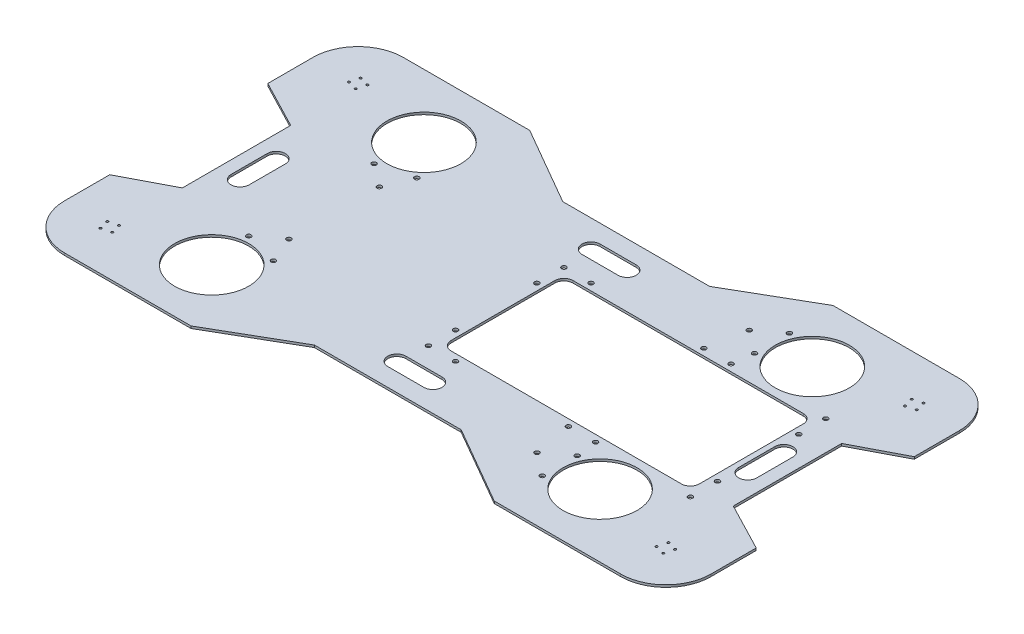
from build123d import *

# Parameters (mm, degrees)
SKETCH1_R           = 52.07
SKETCH1_R_2         = 1.575
BOSS_EXTRUDE1_DEPTH = 3.175
SKETCH2_R           = 3.2639
CUT_EXTRUDE1_DEPTH  = 4.175
SKETCH3_R           = 3.2639
CUT_EXTRUDE2_DEPTH  = 4.175
CUT_EXTRUDE3_DEPTH  = 4.175
CUT_EXTRUDE4_DEPTH  = 4.175


with BuildPart() as part:
    # Sketch1 → Boss-Extrude1 (new body)
    with BuildSketch(Plane(origin=(0, 0, 0), x_dir=(1, 0, 0), z_dir=(0, 1, 0))):
        with BuildLine():
            Line((387.35, 76.2), (387.35, -76.2))
            Line((387.35, -76.2), (454.496015193, -111.125))
            Line((454.496015193, -111.125), (454.496015193, -174.625))
            ThreePointArc((454.496015193, -174.625), (435.897295799, -219.526280605), (390.996015193, -238.125))
            Line((390.996015193, -238.125), (213.196015193, -238.125))
            Line((213.196015193, -238.125), (103.210788913, -174.625))
            Line((103.210788913, -174.625), (-103.210788913, -174.625))
            Line((-103.210788913, -174.625), (-213.196015193, -238.125))
            Line((-213.196015193, -238.125), (-390.996015193, -238.125))
            ThreePointArc((-390.996015193, -238.125), (-435.897295799, -219.526280605), (-454.496015193, -174.625))
            Line((-454.496015193, -174.625), (-454.496015193, -111.125))
            Line((-454.496015193, -111.125), (-387.35, -76.2))
            Line((-387.35, -76.2), (-387.35, 76.2))
            Line((-387.35, 76.2), (-454.496015193, 111.125))
            Line((-454.496015193, 111.125), (-454.496015193, 174.625))
            ThreePointArc((-454.496015193, 174.625), (-435.897295799, 219.526280605), (-390.996015193, 238.125))
            Line((-390.996015193, 238.125), (-213.196015193, 238.125))
            Line((-213.196015193, 238.125), (-103.210788913, 174.625))
            Line((-103.210788913, 174.625), (103.210788913, 174.625))
            Line((103.210788913, 174.625), (213.196015193, 238.125))
            Line((213.196015193, 238.125), (390.996015193, 238.125))
            ThreePointArc((390.996015193, 238.125), (435.897295799, 219.526280605), (454.496015193, 174.625))
            Line((454.496015193, 174.625), (454.496015193, 111.125))
            Line((454.496015193, 111.125), (387.35, 76.2))
        make_face()
        with Locations((273.05, 149.225)):
            Circle(SKETCH1_R, mode=Mode.SUBTRACT)
        with Locations((273.05, -149.225)):
            Circle(SKETCH1_R, mode=Mode.SUBTRACT)
        with Locations((-273.05, 149.225)):
            Circle(SKETCH1_R, mode=Mode.SUBTRACT)
        with Locations((-273.05, -149.225)):
            Circle(SKETCH1_R, mode=Mode.SUBTRACT)
        with Locations((382.768773857, 179.375)):
            Circle(SKETCH1_R_2, mode=Mode.SUBTRACT)
        with Locations((395.746015193, 182.852241336)):
            Circle(SKETCH1_R_2, mode=Mode.SUBTRACT)
        with Locations((399.223256529, 169.875)):
            Circle(SKETCH1_R_2, mode=Mode.SUBTRACT)
        with Locations((386.246015193, 166.397758664)):
            Circle(SKETCH1_R_2, mode=Mode.SUBTRACT)
        with Locations((386.246015193, -166.397758664)):
            Circle(SKETCH1_R_2, mode=Mode.SUBTRACT)
        with Locations((399.223256529, -169.875)):
            Circle(SKETCH1_R_2, mode=Mode.SUBTRACT)
        with Locations((395.746015193, -182.852241336)):
            Circle(SKETCH1_R_2, mode=Mode.SUBTRACT)
        with Locations((382.768773857, -179.375)):
            Circle(SKETCH1_R_2, mode=Mode.SUBTRACT)
        with Locations((-399.223256529, 169.875)):
            Circle(SKETCH1_R_2, mode=Mode.SUBTRACT)
        with Locations((-395.746015193, 182.852241336)):
            Circle(SKETCH1_R_2, mode=Mode.SUBTRACT)
        with Locations((-382.768773857, 179.375)):
            Circle(SKETCH1_R_2, mode=Mode.SUBTRACT)
        with Locations((-386.246015193, 166.397758664)):
            Circle(SKETCH1_R_2, mode=Mode.SUBTRACT)
        with Locations((-386.246015193, -166.397758664)):
            Circle(SKETCH1_R_2, mode=Mode.SUBTRACT)
        with Locations((-399.223256529, -169.875)):
            Circle(SKETCH1_R_2, mode=Mode.SUBTRACT)
        with Locations((-382.768773857, -179.375)):
            Circle(SKETCH1_R_2, mode=Mode.SUBTRACT)
        with Locations((-395.746015193, -182.852241336)):
            Circle(SKETCH1_R_2, mode=Mode.SUBTRACT)
    extrude(amount=BOSS_EXTRUDE1_DEPTH)

    # Sketch2 → Cut-Extrude1 (cut, through all)
    with BuildSketch(Plane(origin=(0, 3.175, 0), x_dir=(1, 0, 0), z_dir=(0, 1, 0))):
        with Locations((346.075, 95.25)):
            Circle(SKETCH2_R)
        with Locations((346.075, 57.15)):
            Circle(SKETCH2_R)
        with Locations((212.725, 95.25)):
            Circle(SKETCH2_R)
        with Locations((174.625, 95.25)):
            Circle(SKETCH2_R)
        with Locations((15.875, 95.25)):
            Circle(SKETCH2_R)
        with Locations((-22.225, 95.25)):
            Circle(SKETCH2_R)
        with Locations((-22.225, 57.15)):
            Circle(SKETCH2_R)
        with Locations((346.075, -57.15)):
            Circle(SKETCH2_R)
        with Locations((346.075, -95.25)):
            Circle(SKETCH2_R)
        with Locations((212.725, -95.25)):
            Circle(SKETCH2_R)
        with Locations((174.625, -95.25)):
            Circle(SKETCH2_R)
        with Locations((15.875, -95.25)):
            Circle(SKETCH2_R)
        with Locations((-22.225, -95.25)):
            Circle(SKETCH2_R)
        with Locations((-22.225, -57.15)):
            Circle(SKETCH2_R)
        with BuildLine():
            Line((0, 85.725), (323.85, 85.725))
            ThreePointArc((323.85, 85.725), (332.830256121, 82.005256121), (336.55, 73.025))
            Line((336.55, 73.025), (336.55, -73.025))
            ThreePointArc((336.55, -73.025), (332.830256121, -82.005256121), (323.85, -85.725))
            Line((323.85, -85.725), (0, -85.725))
            ThreePointArc((0, -85.725), (-8.980256121, -82.005256121), (-12.7, -73.025))
            Line((-12.7, -73.025), (-12.7, 73.025))
            ThreePointArc((-12.7, 73.025), (-8.980256121, 82.005256121), (0, 85.725))
        make_face()
    extrude(amount=-CUT_EXTRUDE1_DEPTH, mode=Mode.SUBTRACT)

    # Sketch3 → Cut-Extrude2 (cut, through all)
    with BuildSketch(Plane(origin=(0, 3.175, 0), x_dir=(1, 0, 0), z_dir=(0, 1, 0))):
        with Locations((184.362499956, 149.225)):
            Circle(SKETCH3_R)
        with Locations((-250.095985926, 63.559453238)):
            Circle(SKETCH3_R)
        with Locations((184.362499956, -149.225)):
            Circle(SKETCH3_R)
        with Locations((-250.095985926, -63.559453238)):
            Circle(SKETCH3_R)
        with Locations((216.336503702, 173.759515988)):
            Circle(SKETCH3_R)
        with Locations((216.336503702, 124.690484012)):
            Circle(SKETCH3_R)
        with Locations((-282.069989672, 88.093969226)):
            Circle(SKETCH3_R)
        with Locations((-234.672944416, 100.793969226)):
            Circle(SKETCH3_R)
        with Locations((216.336503702, -124.690484012)):
            Circle(SKETCH3_R)
        with Locations((216.336503702, -173.759515988)):
            Circle(SKETCH3_R)
        with Locations((-234.672944416, -100.793969226)):
            Circle(SKETCH3_R)
        with Locations((-282.069989672, -88.093969226)):
            Circle(SKETCH3_R)
    extrude(amount=-CUT_EXTRUDE2_DEPTH, mode=Mode.SUBTRACT)

    # Sketch4 → Cut-Extrude3 (cut, through all)
    with BuildSketch(Plane(origin=(0, 3.175, 0), x_dir=(1, 0, 0), z_dir=(0, 1, 0))):
        with BuildLine():
            Line((-344.17, 25.4), (-344.17, -25.4))
            ThreePointArc((-344.17, -25.4), (-356.87, -38.1), (-369.57, -25.4))
            Line((-369.57, -25.4), (-369.57, 25.4))
            ThreePointArc((-369.57, 25.4), (-356.87, 38.1), (-344.17, 25.4))
        make_face()
        with BuildLine():
            Line((344.17, 25.4), (344.17, -25.4))
            ThreePointArc((344.17, -25.4), (356.87, -38.1), (369.57, -25.4))
            Line((369.57, -25.4), (369.57, 25.4))
            ThreePointArc((369.57, 25.4), (356.87, 38.1), (344.17, 25.4))
        make_face()
    extrude(amount=-CUT_EXTRUDE3_DEPTH, mode=Mode.SUBTRACT)

    # Sketch5 → Cut-Extrude4 (cut, through all)
    with BuildSketch(Plane(origin=(0, 3.175, 0), x_dir=(1, 0, 0), z_dir=(0, 1, 0))):
        with BuildLine():
            Line((-25.4, 149.225), (25.4, 149.225))
            ThreePointArc((25.4, 149.225), (38.1, 136.525), (25.4, 123.825))
            Line((25.4, 123.825), (-25.4, 123.825))
            ThreePointArc((-25.4, 123.825), (-38.1, 136.525), (-25.4, 149.225))
        make_face()
        with BuildLine():
            Line((-25.4, -149.225), (25.4, -149.225))
            ThreePointArc((25.4, -149.225), (38.1, -136.525), (25.4, -123.825))
            Line((25.4, -123.825), (-25.4, -123.825))
            ThreePointArc((-25.4, -123.825), (-38.1, -136.525), (-25.4, -149.225))
        make_face()
    extrude(amount=-CUT_EXTRUDE4_DEPTH, mode=Mode.SUBTRACT)


solid = part.part
